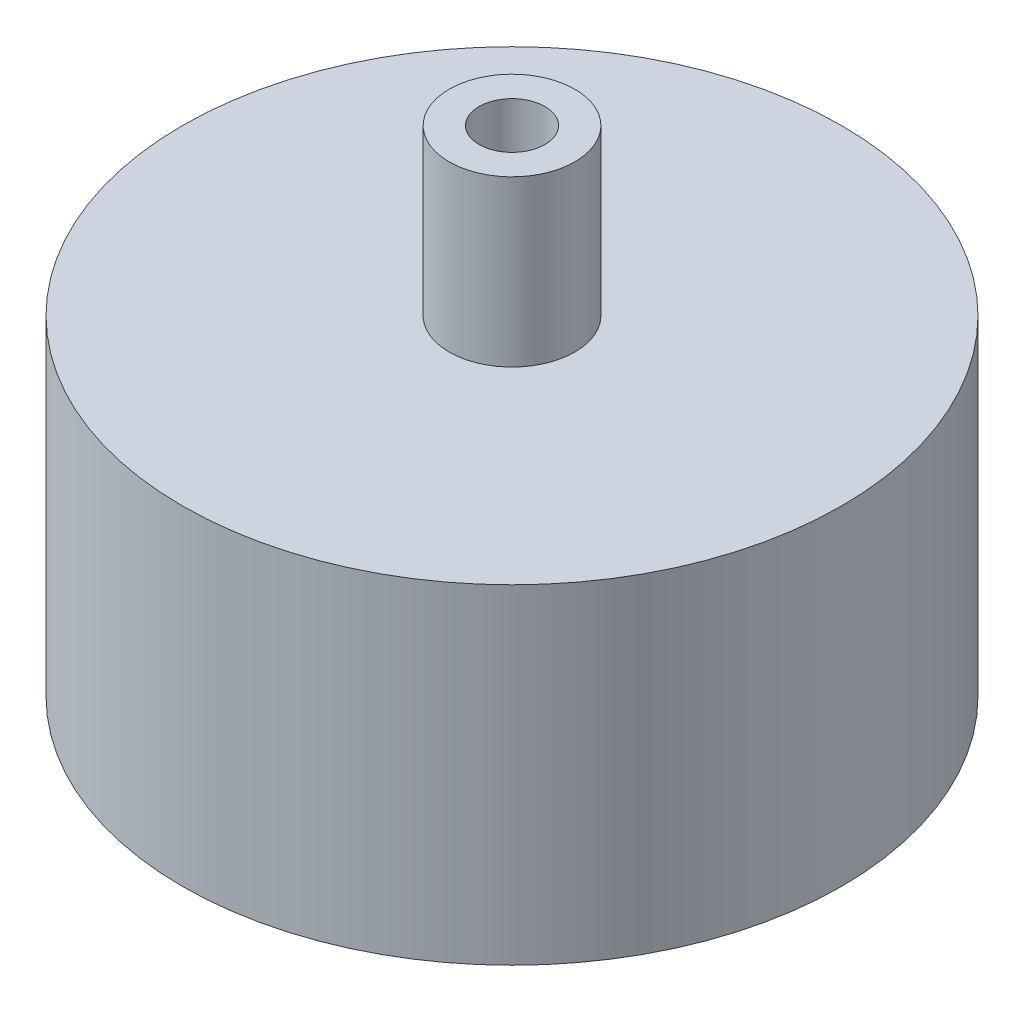
from build123d import *

# Parameters (mm, degrees)
SKETCH_1_R      = 30
EXTRUDE_1_DEPTH = 30
SKETCH_2_R      = 5.725
SKETCH_2_R_2    = 3
EXTRUDE_2_DEPTH = 15


with BuildPart() as part:
    # 草图1 → 凸台-拉伸1 (new body)
    with BuildSketch(Plane(origin=(0, 0, 0), x_dir=(1, 0, 0), z_dir=(0, 1, 0))):
        Circle(SKETCH_1_R)
    extrude(amount=EXTRUDE_1_DEPTH)

    # 草图2 → 凸台-拉伸2 (add)
    with BuildSketch(Plane(origin=(0, 30, 0), x_dir=(1, 0, 0), z_dir=(0, 1, 0))):
        Circle(SKETCH_2_R)
        Circle(SKETCH_2_R_2, mode=Mode.SUBTRACT)
    extrude(amount=EXTRUDE_2_DEPTH)


solid = part.part
